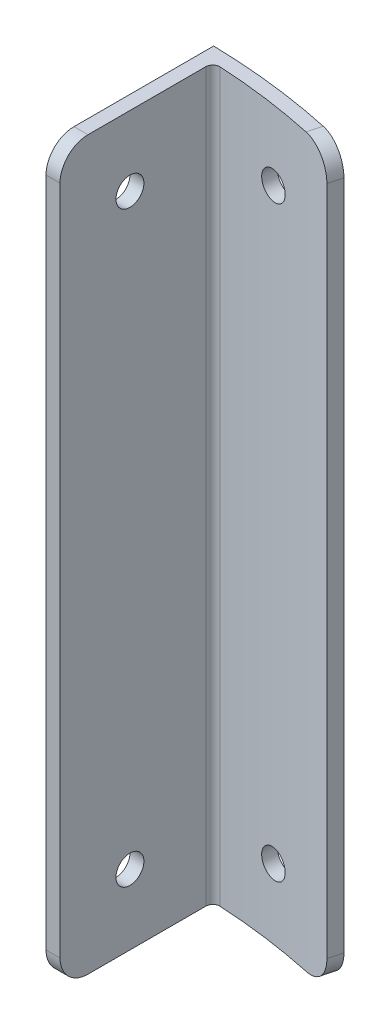
from build123d import *

# Parameters (mm, degrees)
BOSS_EXTRUDE1_DEPTH            = 165.1
FILLET1_R                      = 6.35
FILLET2_R                      = 1.5875
SKETCH2_R                      = 3.175
CUT_EXTRUDE1_DEPTH             = 35.385404243
CUT_EXTRUDE2_REACH             = 39.698
SKETCH3_R                      = 3.175
CUT_EXTRUDE2_DIRECTION_2_REACH = 6.755


with BuildPart() as part:
    # Sketch1 → Boss-Extrude1 (new body)
    with BuildSketch(Plane(origin=(0, 0, 0), x_dir=(1, 0, 0), z_dir=(0, 1, 0))):
        with BuildLine():
            ThreePointArc((6.477, 145.90630888), (21.802443449, 144.413489535), (36.88554448, 141.315459552))
            Line((36.88554448, 141.315459552), (37.687404143, 144.38753476))
            ThreePointArc((37.687404143, 144.38753476), (20.634801681, 147.791425951), (3.302, 149.188462761))
            Line((3.302, 149.188462761), (3.302, 146.012668272))
            ThreePointArc((3.302, 146.012668272), (4.889789191, 145.968121388), (6.477, 145.90630888))
        make_face()
        with BuildLine():
            Line((3.302, 146.012668272), (3.302, 111.125))
            Line((3.302, 111.125), (6.477, 111.125))
            Line((6.477, 111.125), (6.477, 145.90630888))
            ThreePointArc((6.477, 145.90630888), (4.889789191, 145.968121388), (3.302, 146.012668272))
        make_face()
    extrude(amount=BOSS_EXTRUDE1_DEPTH)

    # Fillet1
    fillet1_edges = [part.edges().sort_by_distance(p)[0] for p in [
        (37.286474311, 165.1, -142.851497156),
        (4.8895, 165.1, -111.125),
        (4.8895, 0, -111.125),
        (37.286474311, 0, -142.851497156),
    ]]
    fillet(fillet1_edges, radius=FILLET1_R)

    # Fillet2
    fillet2_edges = [part.edges().sort_by_distance(p)[0] for p in [
        (6.477, 82.55, -145.90630888),
    ]]
    fillet(fillet2_edges, radius=FILLET2_R)

    # Sketch2 → Cut-Extrude1 (cut, through all)
    with BuildSketch(Plane.ZY.offset(-3.302)):
        with Locations((-127, 15.875)):
            Circle(SKETCH2_R)
        with Locations((-127, 149.225)):
            Circle(SKETCH2_R)
    extrude(amount=-CUT_EXTRUDE1_DEPTH, mode=Mode.SUBTRACT)

    # Sketch3 → Cut-Extrude2 (cut, up to next)
    with BuildSketch(Plane(origin=(20.494702071, 0, -146.78799876), x_dir=(-0.990393205, 0, -0.13827979), z_dir=(0.13827979, 0, -0.990393205)), mode=Mode.PRIVATE) as cut_extrude2_sk1:
        with Locations((-1.484470958, 15.875)):
            Circle(SKETCH3_R)
    cut_extrude2_tool1 = extrude(cut_extrude2_sk1.sketch, amount=-CUT_EXTRUDE2_REACH, mode=Mode.PRIVATE) & part.part
    add(cut_extrude2_tool1.solids().sort_by_distance((21.964912, 15.875, -146.582726))[0], mode=Mode.SUBTRACT)
    # Sketch3 → Cut-Extrude2 (cut, up to next)
    with BuildSketch(Plane(origin=(20.494702071, 0, -146.78799876), x_dir=(-0.990393205, 0, -0.13827979), z_dir=(0.13827979, 0, -0.990393205)), mode=Mode.PRIVATE) as cut_extrude2_sk2:
        with Locations((-1.484470958, 149.225)):
            Circle(SKETCH3_R)
    cut_extrude2_tool2 = extrude(cut_extrude2_sk2.sketch, amount=-CUT_EXTRUDE2_REACH, mode=Mode.PRIVATE) & part.part
    add(cut_extrude2_tool2.solids().sort_by_distance((21.964912, 149.225, -146.582726))[0], mode=Mode.SUBTRACT)

    # Sketch3 → Cut-Extrude2 direction 2 (cut, up to next)
    with BuildSketch(Plane(origin=(20.494702071, 0, -146.78799876), x_dir=(-0.990393205, 0, -0.13827979), z_dir=(0.13827979, 0, -0.990393205)), mode=Mode.PRIVATE) as cut_extrude2_direction_2_sk1:
        with Locations((-1.484470958, 15.875)):
            Circle(SKETCH3_R)
    cut_extrude2_direction_2_tool1 = extrude(cut_extrude2_direction_2_sk1.sketch, amount=CUT_EXTRUDE2_DIRECTION_2_REACH, mode=Mode.PRIVATE) & part.part
    add(cut_extrude2_direction_2_tool1.solids().sort_by_distance((21.964912, 15.875, -146.582726))[0], mode=Mode.SUBTRACT)
    # Sketch3 → Cut-Extrude2 direction 2 (cut, up to next)
    with BuildSketch(Plane(origin=(20.494702071, 0, -146.78799876), x_dir=(-0.990393205, 0, -0.13827979), z_dir=(0.13827979, 0, -0.990393205)), mode=Mode.PRIVATE) as cut_extrude2_direction_2_sk2:
        with Locations((-1.484470958, 149.225)):
            Circle(SKETCH3_R)
    cut_extrude2_direction_2_tool2 = extrude(cut_extrude2_direction_2_sk2.sketch, amount=CUT_EXTRUDE2_DIRECTION_2_REACH, mode=Mode.PRIVATE) & part.part
    add(cut_extrude2_direction_2_tool2.solids().sort_by_distance((21.964912, 149.225, -146.582726))[0], mode=Mode.SUBTRACT)


solid = part.part
